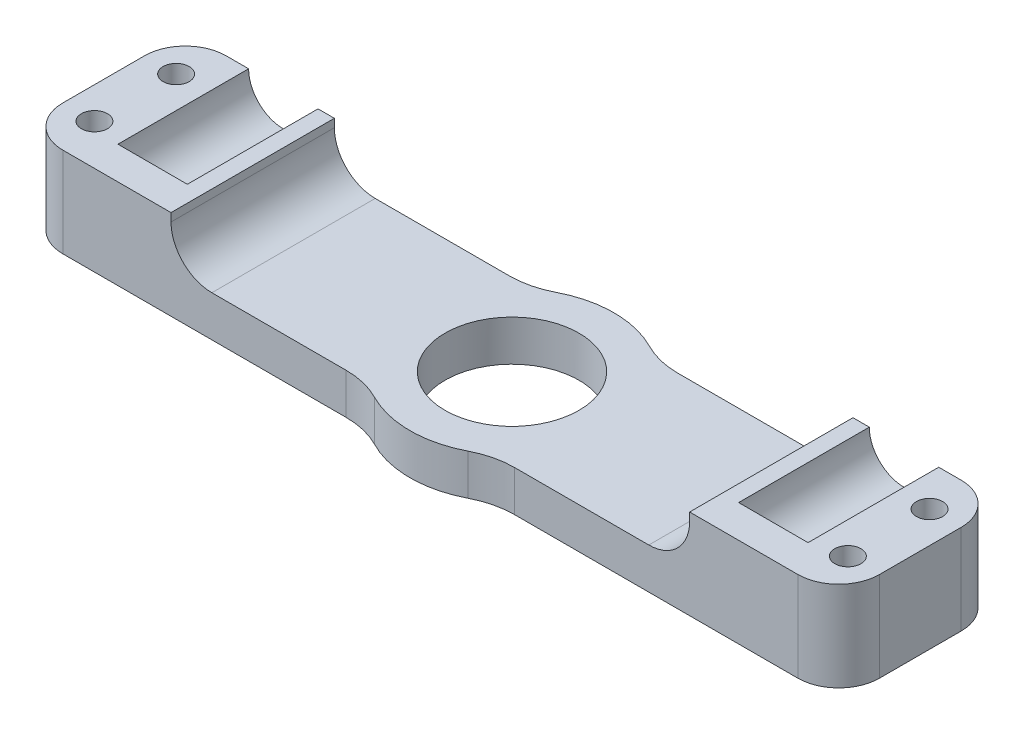
from build123d import *

# Parameters (mm, degrees)
SKETCH1_W               = 88
SKETCH1_H               = 20
BOSS_EXTRUDE1_DEPTH     = 22
SKETCH2_R               = 4.25
CUT_EXTRUDE1_DEPTH      = 21
SKETCH7_R               = 12.5
BOSS_EXTRUDE2_DEPTH     = 22
SKETCH4_R               = 8.2
CUT_EXTRUDE3_DEPTH      = 23
FILLET2_R               = 10
SKETCH9_W               = 27
SKETCH9_H               = 11
CUT_EXTRUDE4_DEPTH      = 89
SKETCH10_W              = 63.5
SKETCH10_H              = 8
CUT_EXTRUDE5_DEPTH      = 13.5
CUT_EXTRUDE5_DEPTH_BACK = 13.5
FILLET3_R               = 5
SKETCH11_W              = 20
SKETCH11_H              = 11
BOSS_EXTRUDE3_DEPTH     = 6
SKETCH12_R              = 1.6
CUT_EXTRUDE6_DEPTH      = 12
FILLET4_R               = 5
BOSS_EXTRUDE4_DEPTH     = 4


with BuildPart() as part:
    # Sketch1 → Boss-Extrude1 (new body)
    with BuildSketch(Plane(origin=(0, 0, 0), x_dir=(1, 0, 0), z_dir=(0, 1, 0))):
        Rectangle(SKETCH1_W, SKETCH1_H)
    extrude(amount=BOSS_EXTRUDE1_DEPTH)

    # Sketch2 → Cut-Extrude1 (cut, through all)
    with BuildSketch(Plane.XY.offset(10)):
        with Locations((-38, 11)):
            Circle(SKETCH2_R)
        with Locations((38, 11)):
            Circle(SKETCH2_R)
    extrude(amount=-CUT_EXTRUDE1_DEPTH, mode=Mode.SUBTRACT)

    # Sketch7 → Boss-Extrude2 (add)
    with BuildSketch(Plane(origin=(0, 22, 0), x_dir=(1, 0, 0), z_dir=(0, 1, 0))):
        Circle(SKETCH7_R)
    extrude(amount=-BOSS_EXTRUDE2_DEPTH)

    # Sketch4 → Cut-Extrude3 (cut, through all)
    with BuildSketch(Plane(origin=(0, 22, 0), x_dir=(1, 0, 0), z_dir=(0, 1, 0))):
        Circle(SKETCH4_R)
    extrude(amount=-CUT_EXTRUDE3_DEPTH, mode=Mode.SUBTRACT)

    # Fillet2
    fillet2_edges = [part.edges().sort_by_distance(p)[0] for p in [
        (7.5, 11, -10),
        (7.5, 11, 10),
        (-7.5, 11, -10),
        (-7.5, 11, 10),
    ]]
    fillet(fillet2_edges, radius=FILLET2_R)

    # Sketch9 → Cut-Extrude4 (cut, through all)
    with BuildSketch(Plane.ZY.offset(44)):
        with Locations((0, 16.5)):
            Rectangle(SKETCH9_W, SKETCH9_H)
    extrude(amount=-CUT_EXTRUDE4_DEPTH, mode=Mode.SUBTRACT)

    # Sketch10 → Cut-Extrude5 (cut, two sides)
    with BuildSketch(Plane.XY) as cut_extrude5_sk:
        with Locations((0, 9)):
            Rectangle(SKETCH10_W, SKETCH10_H)
    extrude(amount=CUT_EXTRUDE5_DEPTH, mode=Mode.SUBTRACT)
    extrude(cut_extrude5_sk.sketch, amount=-CUT_EXTRUDE5_DEPTH_BACK, mode=Mode.SUBTRACT)

    # Fillet3
    fillet3_edges = [part.edges().sort_by_distance(p)[0] for p in [
        (31.75, 5, 0),
        (-31.75, 5, 0),
    ]]
    fillet(fillet3_edges, radius=FILLET3_R)

    # Sketch11 → Boss-Extrude3 (add)
    with BuildSketch(Plane(origin=(44, 0, 0), x_dir=(0, 0, -1), z_dir=(1, 0, 0))):
        with Locations((0, 5.5)):
            Rectangle(SKETCH11_W, SKETCH11_H)
    boss_extrude3 = extrude(amount=BOSS_EXTRUDE3_DEPTH)

    # Sketch12 → Cut-Extrude6 (cut, through all)
    with BuildSketch(Plane(origin=(0, 11, 0), x_dir=(1, 0, 0), z_dir=(0, 1, 0))):
        with Locations((46.125, -5)):
            Circle(SKETCH12_R)
        with Locations((46.125, 5)):
            Circle(SKETCH12_R)
    cut_extrude6 = extrude(amount=-CUT_EXTRUDE6_DEPTH, mode=Mode.SUBTRACT)

    # Mirror1: Boss-Extrude3, Cut-Extrude6 across plane
    add(boss_extrude3.mirror(Plane(origin=(0, 0, 0), x_dir=(0, 0, 1), z_dir=(1, 0, 0))))
    add(cut_extrude6.mirror(Plane(origin=(0, 0, 0), x_dir=(0, 0, 1), z_dir=(1, 0, 0))), mode=Mode.SUBTRACT)

    # Fillet4
    fillet4_edges = [part.edges().sort_by_distance(p)[0] for p in [
        (50, 5.5, -10),
        (50, 5.5, 10),
        (-50, 5.5, 10),
        (-50, 5.5, -10),
    ]]
    fillet(fillet4_edges, radius=FILLET4_R)

    # Sketch13 → Boss-Extrude4 (add)
    with BuildSketch(Plane.XY.offset(10)):
        with BuildLine():
            Line((-42.25, 11), (-33.75, 11))
            ThreePointArc((-33.75, 11), (-38, 6.75), (-42.25, 11))
        make_face()
        with BuildLine():
            Line((33.75, 11), (42.25, 11))
            ThreePointArc((42.25, 11), (38, 6.75), (33.75, 11))
        make_face()
    extrude(amount=-BOSS_EXTRUDE4_DEPTH)


solid = part.part
